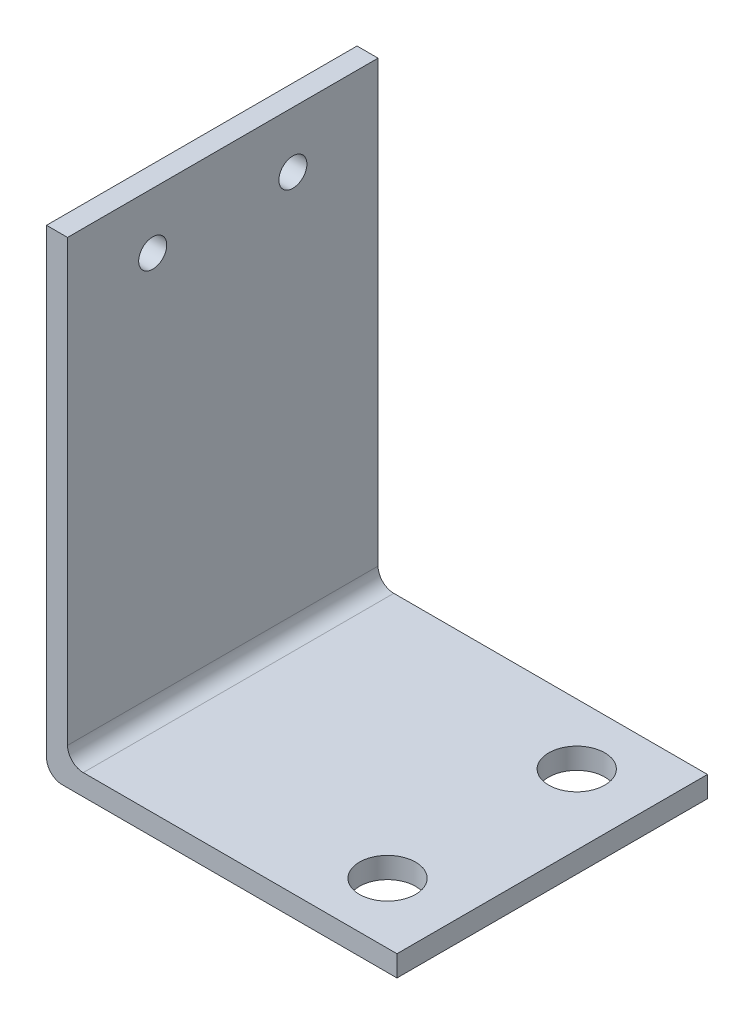
from build123d import *

# Parameters (mm, degrees)
BOSS_EXTRU_1_DEPTH      = 22.15
ESQUISSE2_R             = 2
ENL_V_MAT_EXTRU_1_DEPTH = 2.5
ESQUISSE3_R             = 1
ENL_V_MAT_EXTRU_2_DEPTH = 2.5


with BuildPart() as part:
    # Esquisse1 → Boss.-Extru.1 (new body)
    with BuildSketch(Plane.XY):
        with BuildLine():
            Line((0, 1.122291019), (0, 34))
            Line((0, 34), (1.5, 34))
            Line((1.5, 34), (1.5, 2.622291019))
            ThreePointArc((1.5, 2.622291019), (1.828711429, 1.828711429), (2.622291019, 1.5))
            Line((2.622291019, 1.5), (25, 1.5))
            Line((25, 1.5), (25, 0))
            Line((25, 0), (1.122291019, 0))
            ThreePointArc((1.122291019, 0), (0.328711429, 0.328711429), (0, 1.122291019))
        make_face()
    extrude(amount=BOSS_EXTRU_1_DEPTH)

    # Esquisse2 → Enlèv. mat.-Extru.1 (cut, through all)
    with BuildSketch(Plane(origin=(0, 1.5, 0), x_dir=(1, 0, 0), z_dir=(0, 1, 0))):
        with Locations((20, -4.325)):
            Circle(ESQUISSE2_R)
        with Locations((20, -17.825)):
            Circle(ESQUISSE2_R)
    extrude(amount=-ENL_V_MAT_EXTRU_1_DEPTH, mode=Mode.SUBTRACT)

    # Esquisse3 → Enlèv. mat.-Extru.2 (cut, through all)
    with BuildSketch(Plane(origin=(1.5, 0, 0), x_dir=(0, 0, -1), z_dir=(1, 0, 0))):
        with Locations((-16.075, 30)):
            Circle(ESQUISSE3_R)
        with Locations((-6.075, 30)):
            Circle(ESQUISSE3_R)
    extrude(amount=-ENL_V_MAT_EXTRU_2_DEPTH, mode=Mode.SUBTRACT)


solid = part.part
